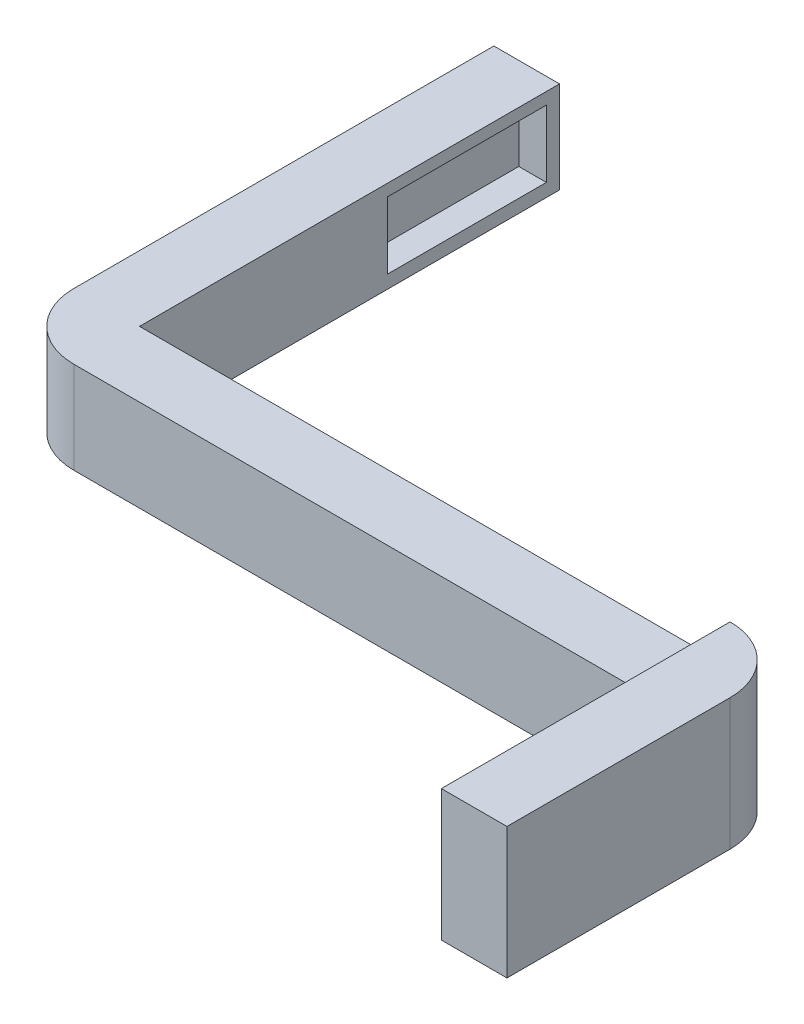
from build123d import *

# Parameters (mm, degrees)
SKETCH1_W           = 45
SKETCH1_H           = 7
BOSS_EXTRUDE1_DEPTH = 5
SKETCH2_W           = 37
SKETCH2_H           = 7
BOSS_EXTRUDE2_DEPTH = 5
FILLET1_R           = 5
SKETCH3_W           = 22
SKETCH3_H           = 10
BOSS_EXTRUDE3_DEPTH = 5
FILLET2_R           = 5
SKETCH4_W           = 12.1
SKETCH4_H           = 5.1
CUT_EXTRUDE1_DEPTH  = 2.1


with BuildPart() as part:
    # Sketch1 → Boss-Extrude1 (new body)
    with BuildSketch(Plane.XY):
        Rectangle(SKETCH1_W, SKETCH1_H)
    extrude(amount=BOSS_EXTRUDE1_DEPTH)

    # Sketch2 → Boss-Extrude2 (add)
    with BuildSketch(Plane.ZY.offset(22.5)):
        with Locations((-13.5, 0)):
            Rectangle(SKETCH2_W, SKETCH2_H)
    extrude(amount=BOSS_EXTRUDE2_DEPTH)

    # Fillet1
    fillet1_edges = [part.edges().sort_by_distance(p)[0] for p in [
        (-27.5, 0, 5),
    ]]
    fillet(fillet1_edges, radius=FILLET1_R)

    # Sketch3 → Boss-Extrude3 (add)
    with BuildSketch(Plane(origin=(22.5, 0, 0), x_dir=(0, 0, -1), z_dir=(1, 0, 0))):
        with Locations((-11, 1.5)):
            Rectangle(SKETCH3_W, SKETCH3_H)
    extrude(amount=BOSS_EXTRUDE3_DEPTH)

    # Fillet2
    fillet2_edges = [part.edges().sort_by_distance(p)[0] for p in [
        (27.5, 1.5, 0),
    ]]
    fillet(fillet2_edges, radius=FILLET2_R)

    # Sketch4 → Cut-Extrude1 (cut)
    with BuildSketch(Plane(origin=(-22.5, 0, 0), x_dir=(0, 0, -1), z_dir=(1, 0, 0))):
        with Locations((24.95, 0.05)):
            Rectangle(SKETCH4_W, SKETCH4_H)
    extrude(amount=-CUT_EXTRUDE1_DEPTH, mode=Mode.SUBTRACT)


solid = part.part
